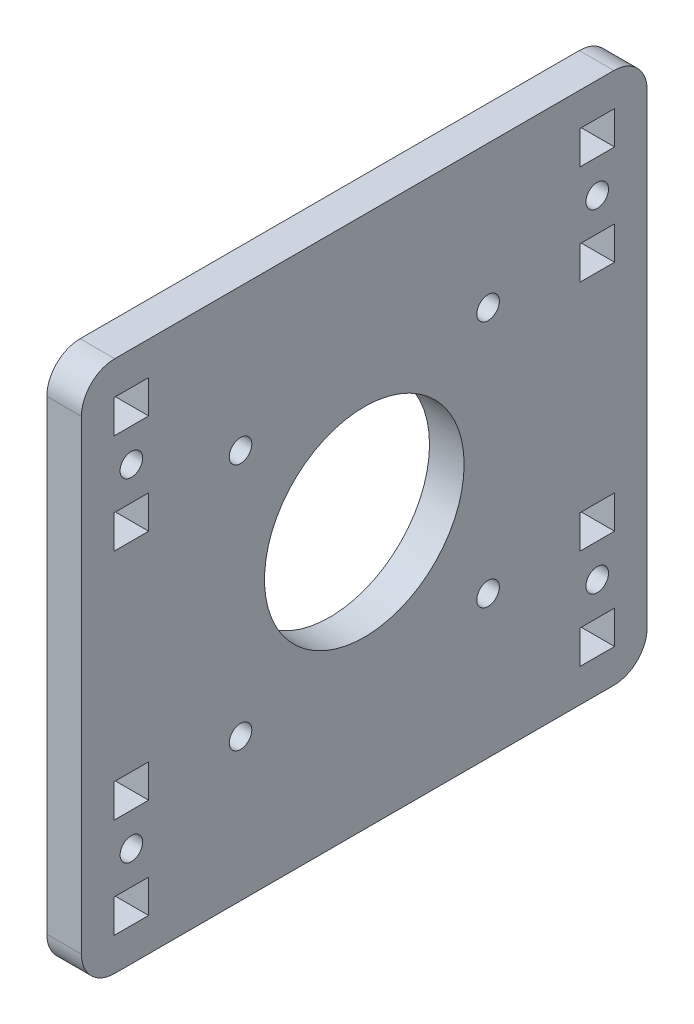
from build123d import *

# Parameters (mm, degrees)
SKETCH1_W                                         = 107.95
SKETCH1_H                                         = 101.6
SKETCH1_R                                         = 19.05
SKETCH1_R_2                                       = 2.15265
SKETCH1_W_2                                       = 6.604
SKETCH1_H_2                                       = 6.35
BOSS_EXTRUDE1_DEPTH                               = 6.604
F_10_32_TAPPED_HOLE1_D                            = 4.0386
F_10_32_TAPPED_HOLE1_DEPTH                        = 12.0396
F_10_32_TAPPED_HOLE1_TIP                          = 1.213317848
FILLET1_R                                         = 6.35
CSK_FOR_8_FLAT_HEAD_SOCKET_CAP_SCREW2_D           = 4.3053
CSK_FOR_8_FLAT_HEAD_SOCKET_CAP_SCREW2_CSINK_D     = 9.1186
CSK_FOR_8_FLAT_HEAD_SOCKET_CAP_SCREW2_CSINK_ANGLE = 82


with BuildPart() as part:
    # Sketch1 → Boss-Extrude1 (new body)
    with BuildSketch(Plane(origin=(0, 0, 0), x_dir=(0, 0, -1), z_dir=(1, 0, 0))):
        Rectangle(SKETCH1_W, SKETCH1_H)
        Circle(SKETCH1_R, mode=Mode.SUBTRACT)
        with Locations((-44.45, 31.75)):
            Circle(SKETCH1_R_2, mode=Mode.SUBTRACT)
        with Locations((-44.45, -31.75)):
            Circle(SKETCH1_R_2, mode=Mode.SUBTRACT)
        with Locations((44.45, 31.75)):
            Circle(SKETCH1_R_2, mode=Mode.SUBTRACT)
        with Locations((44.45, -31.75)):
            Circle(SKETCH1_R_2, mode=Mode.SUBTRACT)
        with Locations((-44.45, 41.275)):
            Rectangle(SKETCH1_W_2, SKETCH1_H_2, mode=Mode.SUBTRACT)
        with Locations((-44.45, 22.225)):
            Rectangle(SKETCH1_W_2, SKETCH1_H_2, mode=Mode.SUBTRACT)
        with Locations((-44.45, -22.225)):
            Rectangle(SKETCH1_W_2, SKETCH1_H_2, mode=Mode.SUBTRACT)
        with Locations((-44.45, -41.275)):
            Rectangle(SKETCH1_W_2, SKETCH1_H_2, mode=Mode.SUBTRACT)
        with Locations((44.45, 41.275)):
            Rectangle(SKETCH1_W_2, SKETCH1_H_2, mode=Mode.SUBTRACT)
        with Locations((44.45, 22.225)):
            Rectangle(SKETCH1_W_2, SKETCH1_H_2, mode=Mode.SUBTRACT)
        with Locations((44.45, -41.275)):
            Rectangle(SKETCH1_W_2, SKETCH1_H_2, mode=Mode.SUBTRACT)
        with Locations((44.45, -22.225)):
            Rectangle(SKETCH1_W_2, SKETCH1_H_2, mode=Mode.SUBTRACT)
    extrude(amount=BOSS_EXTRUDE1_DEPTH)

    # #10-32 Tapped Hole1
    with Locations(Plane(origin=(6.604, 0, 0), x_dir=(0, 0, -1), z_dir=(1, 0, 0))):
        with Locations((-23.622, 23.622), (23.622, 23.622), (-23.622, -23.622), (23.622, -23.622)):
            Hole(F_10_32_TAPPED_HOLE1_D / 2, depth=F_10_32_TAPPED_HOLE1_DEPTH)
            with Locations((0, 0, -(F_10_32_TAPPED_HOLE1_DEPTH + F_10_32_TAPPED_HOLE1_TIP / 2))):  # 118° drill point
                Cone(0, F_10_32_TAPPED_HOLE1_D / 2, F_10_32_TAPPED_HOLE1_TIP, mode=Mode.SUBTRACT)

    # Fillet1
    fillet1_edges = [part.edges().sort_by_distance(p)[0] for p in [
        (3.302, -50.8, -53.975),
        (3.302, -50.8, 53.975),
        (3.302, 50.8, 53.975),
        (3.302, 50.8, -53.975),
    ]]
    fillet(fillet1_edges, radius=FILLET1_R)

    # CSK for #8 Flat Head Socket Cap Screw2 (through all)
    with Locations(Plane.ZY):
        with Locations((-44.45, 31.75), (-23.622, 23.622), (23.622, 23.622), (44.45, 31.75), (23.622, -23.622), (-23.622, -23.622), (-44.45, -31.75), (44.45, -31.75)):
            CounterSinkHole(CSK_FOR_8_FLAT_HEAD_SOCKET_CAP_SCREW2_D / 2, CSK_FOR_8_FLAT_HEAD_SOCKET_CAP_SCREW2_CSINK_D / 2, counter_sink_angle=CSK_FOR_8_FLAT_HEAD_SOCKET_CAP_SCREW2_CSINK_ANGLE)


solid = part.part
